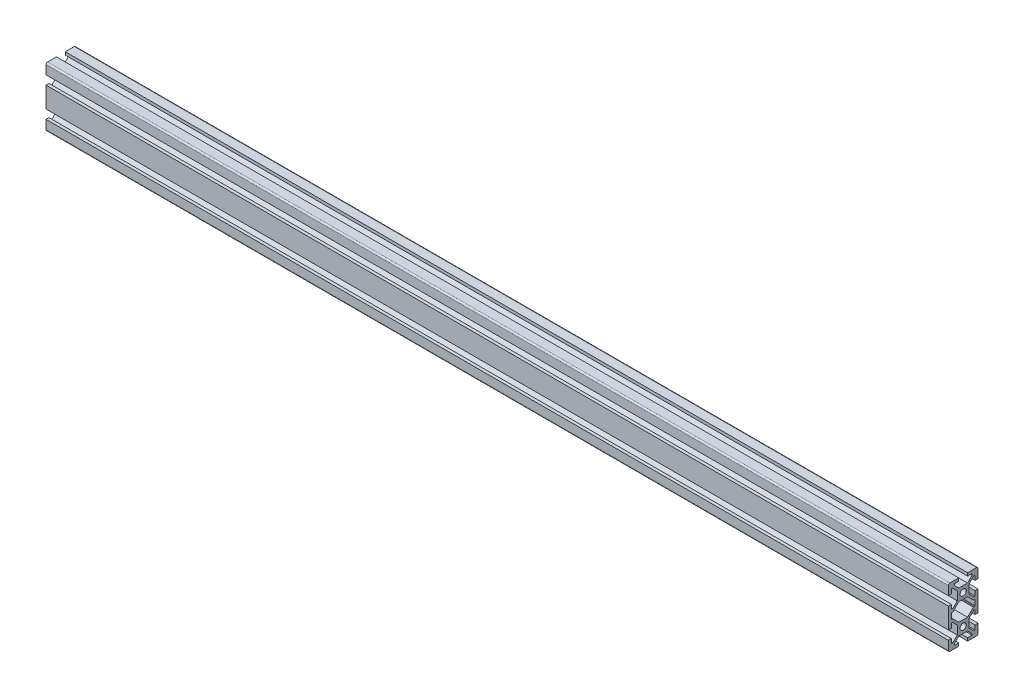
from build123d import *

# Parameters (mm, degrees)
SKETCH1_R           = 2.1
BOSS_EXTRUDE1_DEPTH = 609


with BuildPart() as part:
    # Sketch1 → Boss-Extrude1 (new body)
    with BuildSketch(Plane(origin=(0, 0, 0), x_dir=(0, 0, -1), z_dir=(1, 0, 0))):
        with BuildLine():
            Line((-10, -13), (-10, -19))
            ThreePointArc((-10, -19), (-9.707106781, -19.707106781), (-9, -20))
            Line((-9, -20), (-3, -20))
            Line((-3, -20), (-3, -18))
            Line((-3, -18), (-6, -18))
            Line((-6, -18), (-6, -17.060660172))
            Line((-6, -17.060660172), (-2.939339828, -14))
            Line((-2.939339828, -14), (2.939339828, -14))
            Line((2.939339828, -14), (6, -17.060660172))
            Line((6, -17.060660172), (6, -18))
            Line((6, -18), (3, -18))
            Line((3, -18), (3, -20))
            Line((3, -20), (9, -20))
            ThreePointArc((9, -20), (9.707106781, -19.707106781), (10, -19))
            Line((10, -19), (10, -13))
            Line((10, -13), (8, -13))
            Line((8, -13), (8, -16))
            Line((8, -16), (7.060660172, -16))
            Line((7.060660172, -16), (4, -12.939339828))
            Line((4, -12.939339828), (4, -7.060660172))
            Line((4, -7.060660172), (7.060660172, -4))
            Line((7.060660172, -4), (8, -4))
            Line((8, -4), (8, -7))
            Line((8, -7), (10, -7))
            Line((10, -7), (10, 7))
            Line((10, 7), (8, 7))
            Line((8, 7), (8, 4))
            Line((8, 4), (7.060660172, 4))
            Line((7.060660172, 4), (4, 7.060660172))
            Line((4, 7.060660172), (4, 12.939339828))
            Line((4, 12.939339828), (7.060660172, 16))
            Line((7.060660172, 16), (8, 16))
            Line((8, 16), (8, 13))
            Line((8, 13), (10, 13))
            Line((10, 13), (10, 19))
            ThreePointArc((10, 19), (9.707106781, 19.707106781), (9, 20))
            Line((9, 20), (3, 20))
            Line((3, 20), (3, 18))
            Line((3, 18), (6, 18))
            Line((6, 18), (6, 17.060660172))
            Line((6, 17.060660172), (2.939339828, 14))
            Line((2.939339828, 14), (-2.939339828, 14))
            Line((-2.939339828, 14), (-6, 17.060660172))
            Line((-6, 17.060660172), (-6, 18))
            Line((-6, 18), (-3, 18))
            Line((-3, 18), (-3, 20))
            Line((-3, 20), (-9, 20))
            ThreePointArc((-9, 20), (-9.707106781, 19.707106781), (-10, 19))
            Line((-10, 19), (-10, 13))
            Line((-10, 13), (-8, 13))
            Line((-8, 13), (-8, 16))
            Line((-8, 16), (-7.060660172, 16))
            Line((-7.060660172, 16), (-4, 12.939339828))
            Line((-4, 12.939339828), (-4, 7.060660172))
            Line((-4, 7.060660172), (-7.060660172, 4))
            Line((-7.060660172, 4), (-8, 4))
            Line((-8, 4), (-8, 7))
            Line((-8, 7), (-10, 7))
            Line((-10, 7), (-10, -7))
            Line((-10, -7), (-8, -7))
            Line((-8, -7), (-8, -4))
            Line((-8, -4), (-7.060660172, -4))
            Line((-7.060660172, -4), (-4, -7.060660172))
            Line((-4, -7.060660172), (-4, -12.939339828))
            Line((-4, -12.939339828), (-7.060660172, -16))
            Line((-7.060660172, -16), (-8, -16))
            Line((-8, -16), (-8, -13))
            Line((-8, -13), (-10, -13))
        make_face()
        with Locations((0, 10)):
            Circle(SKETCH1_R, mode=Mode.SUBTRACT)
        with Locations((0, -10)):
            Circle(SKETCH1_R, mode=Mode.SUBTRACT)
        with BuildLine():
            Line((-8, 1.7), (-8, -1.7))
            ThreePointArc((-8, -1.7), (-7.912132034, -1.912132034), (-7.7, -2))
            Line((-7.7, -2), (-7.063603897, -2))
            ThreePointArc((-7.063603897, -2), (-6.948798867, -2.02283614), (-6.851471863, -2.087867966))
            Line((-6.851471863, -2.087867966), (-2.939339828, -6))
            Line((-2.939339828, -6), (2.939339828, -6))
            Line((2.939339828, -6), (6.851471863, -2.087867966))
            ThreePointArc((6.851471863, -2.087867966), (6.948798867, -2.02283614), (7.063603897, -2))
            Line((7.063603897, -2), (7.7, -2))
            ThreePointArc((7.7, -2), (7.912132034, -1.912132034), (8, -1.7))
            Line((8, -1.7), (8, 1.7))
            ThreePointArc((8, 1.7), (7.912132034, 1.912132034), (7.7, 2))
            Line((7.7, 2), (7.063603897, 2))
            ThreePointArc((7.063603897, 2), (6.948798867, 2.02283614), (6.851471863, 2.087867966))
            Line((6.851471863, 2.087867966), (2.939339828, 6))
            Line((2.939339828, 6), (-2.939339828, 6))
            Line((-2.939339828, 6), (-6.851471863, 2.087867966))
            ThreePointArc((-6.851471863, 2.087867966), (-6.948798867, 2.02283614), (-7.063603897, 2))
            Line((-7.063603897, 2), (-7.7, 2))
            ThreePointArc((-7.7, 2), (-7.912132034, 1.912132034), (-8, 1.7))
        make_face(mode=Mode.SUBTRACT)
    extrude(amount=BOSS_EXTRUDE1_DEPTH)


solid = part.part
